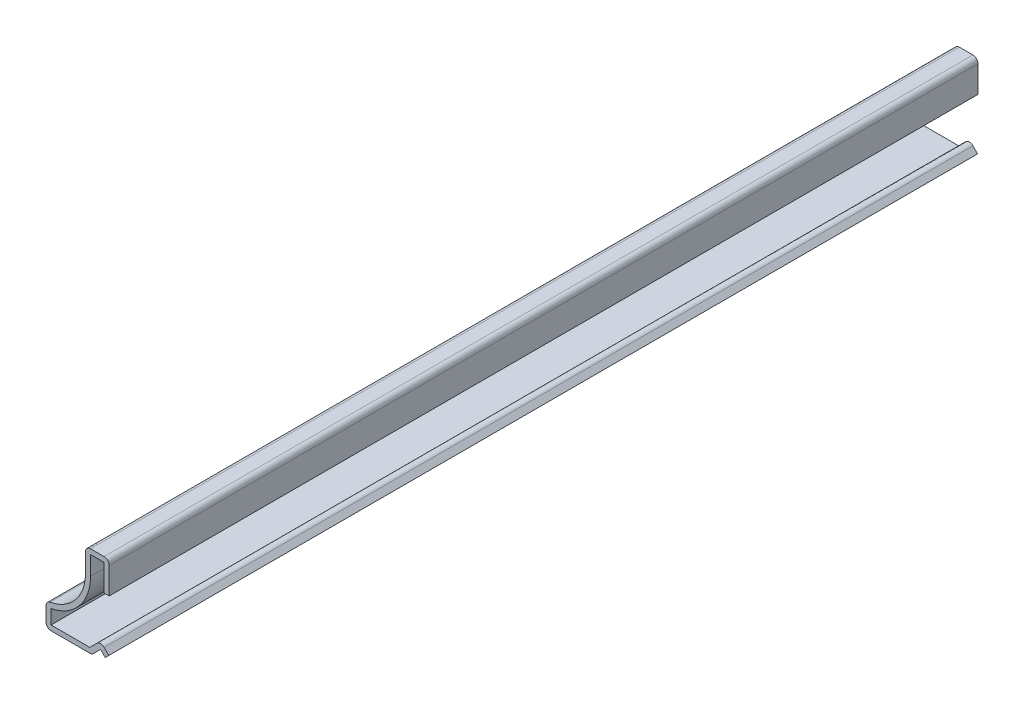
from build123d import *

# Parameters (mm, degrees)
BOSS_EXTRUDE1_DEPTH = 174.625
FILLET1_R           = 1.016


with BuildPart() as part:
    # Sketch1 → Boss-Extrude1 (new body)
    with BuildSketch(Plane.XY):
        with BuildLine():
            Line((0, 11.90625), (0, 18.25625))
            Line((0, 18.25625), (-4.7625, 18.25625))
            Line((-4.7625, 18.25625), (-4.7625, 13.4575956))
            ThreePointArc((-4.7625, 13.4575956), (-7.045294516, 7.570988051), (-12.7, 4.7625))
            Line((-12.7, 4.7625), (-12.7, 0))
            Line((-12.7, 0), (-3.476318041, 0))
            Line((-3.476318041, 0), (-1.738159021, 1.738159021))
            Line((-1.738159021, 1.738159021), (-0.79375, 0.79375))
            Line((-0.79375, 0.79375), (-0.07532951, 1.51217049))
            Line((-0.07532951, 1.51217049), (-1.738159021, 3.175))
            Line((-1.738159021, 3.175), (-3.897159021, 1.016))
            Line((-3.897159021, 1.016), (-11.684, 1.016))
            Line((-11.684, 1.016), (-11.684, 3.879825113))
            ThreePointArc((-11.684, 3.879825113), (-5.988786034, 7.237917278), (-3.7465, 13.4575956))
            Line((-3.7465, 13.4575956), (-3.7465, 17.24025))
            Line((-3.7465, 17.24025), (-1.016, 17.24025))
            Line((-1.016, 17.24025), (-1.016, 11.90625))
            Line((-1.016, 11.90625), (0, 11.90625))
        make_face()
    extrude(amount=-BOSS_EXTRUDE1_DEPTH)

    # Fillet1
    fillet1_edges = [part.edges().sort_by_distance(p)[0] for p in [
        (-1.738159021, 3.175, -87.3125),
        (-3.476318041, 0, -87.3125),
        (-12.7, 0, -87.3125),
        (-12.7, 4.7625, -87.3125),
        (-4.7625, 18.25625, -87.3125),
        (0, 18.25625, -87.3125),
    ]]
    fillet(fillet1_edges, radius=FILLET1_R)


solid = part.part
